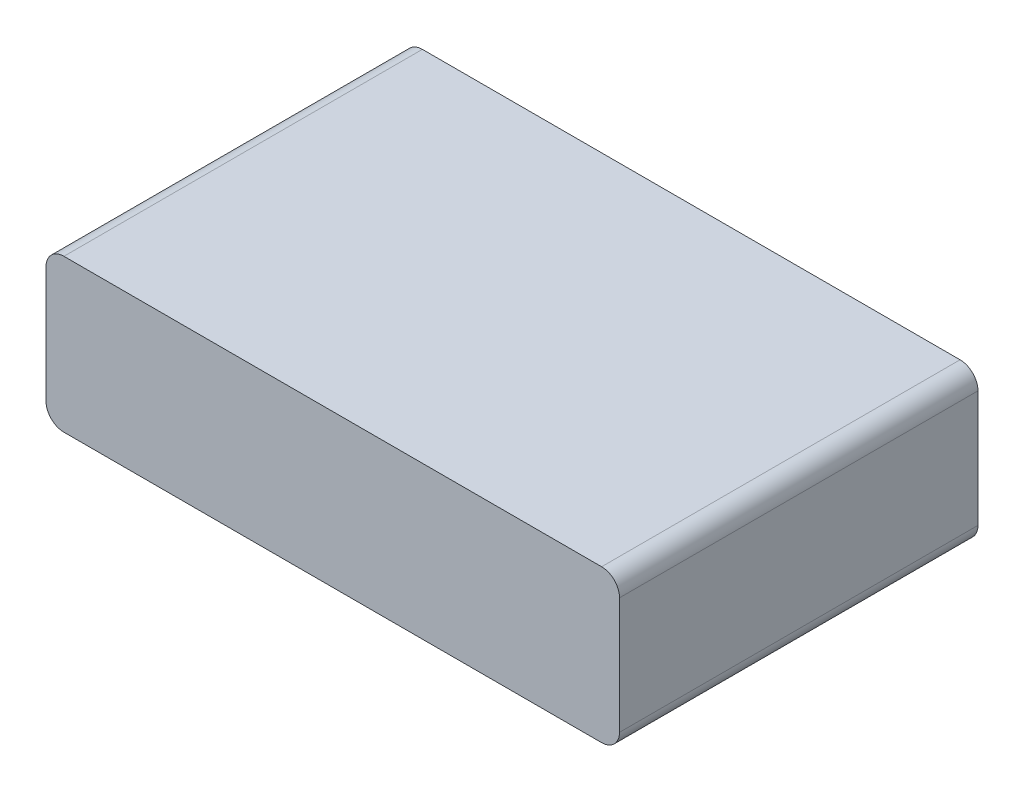
from build123d import *

# Parameters (mm, degrees)
SKETCH1_W           = 64
SKETCH1_H           = 40
BOSS_EXTRUDE1_DEPTH = 8.5
FILLET1_R           = 2


with BuildPart() as part:
    # Sketch1 → Boss-Extrude1 (new body, symmetric)
    with BuildSketch(Plane(origin=(0, 0, 0), x_dir=(1, 0, 0), z_dir=(0, 1, 0))):
        Rectangle(SKETCH1_W, SKETCH1_H)
    extrude(amount=BOSS_EXTRUDE1_DEPTH, both=True)

    # Fillet1
    fillet1_edges = [part.edges().sort_by_distance(p)[0] for p in [
        (-32, 8.5, 0),
        (32, 8.5, 0),
        (-32, -8.5, 0),
        (32, -8.5, 0),
    ]]
    fillet(fillet1_edges, radius=FILLET1_R)


solid = part.part
